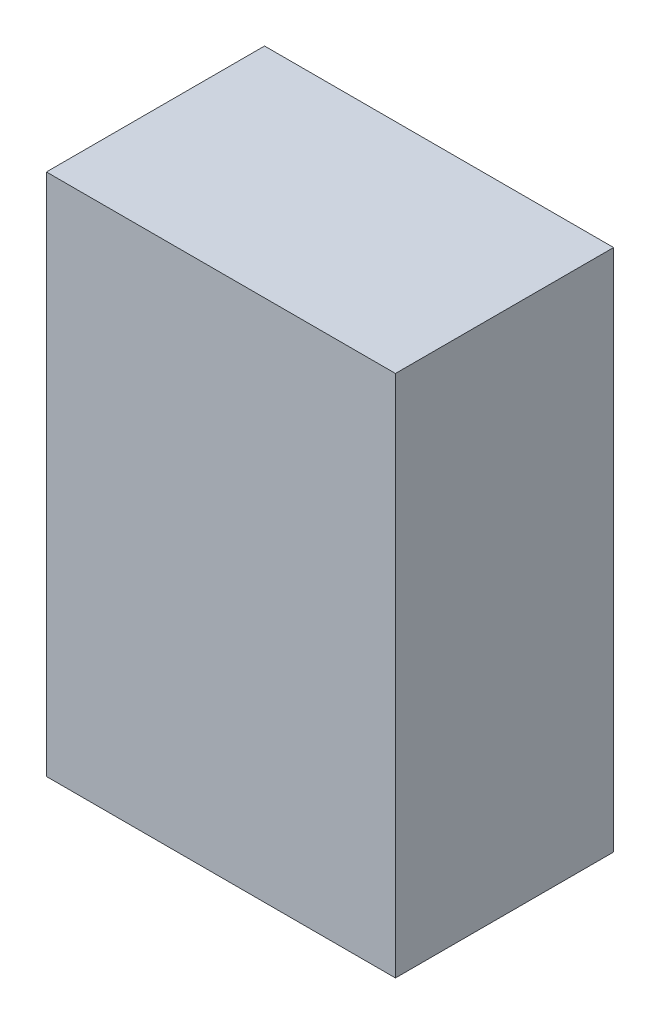
from build123d import *

# Parameters (mm, degrees)
SKETCH1_W                = 8000
SKETCH1_H                = 5000
BOSS_EXTRUDE1_DEPTH      = 4000
BOSS_EXTRUDE1_DEPTH_BACK = 8000


with BuildPart() as part:
    # Sketch1 → Boss-Extrude1 (new body, two sides)
    with BuildSketch(Plane(origin=(0, 0, 0), x_dir=(1, 0, 0), z_dir=(0, 1, 0))) as boss_extrude1_sk:
        Rectangle(SKETCH1_W, SKETCH1_H)
    extrude(amount=BOSS_EXTRUDE1_DEPTH)
    extrude(boss_extrude1_sk.sketch, amount=-BOSS_EXTRUDE1_DEPTH_BACK)


solid = part.part
